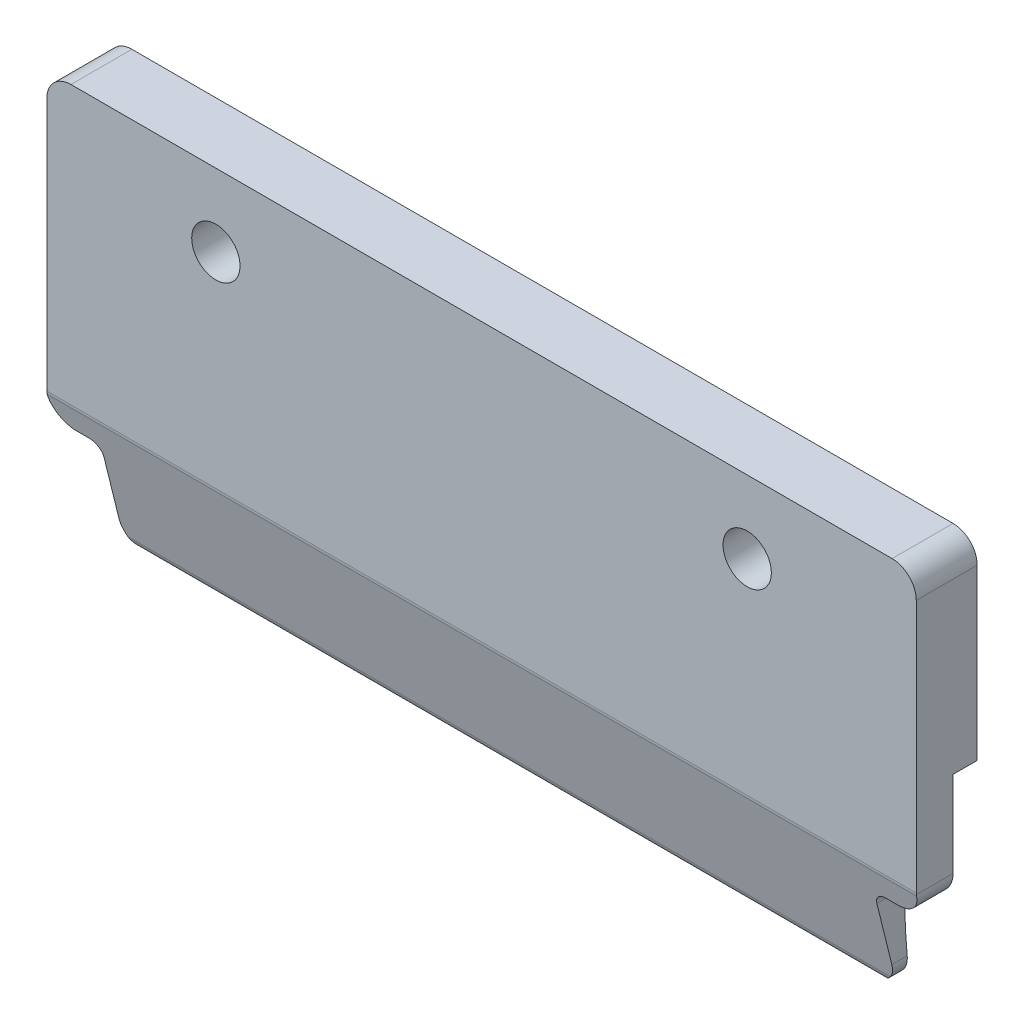
from build123d import *

# Parameters (mm, degrees)
BOSS_EXTRUDE1_DEPTH      = 1.5
BOSS_EXTRUDE1_DEPTH_BACK = 1.2
CUT_EXTRUDE1_DEPTH       = 40
SKETCH11_R               = 1
CUT_EXTRUDE2_DEPTH       = 5


with BuildPart() as part:
    # Sketch1 → Boss-Extrude1 (new body, two sides)
    with BuildSketch(Plane.XY) as boss_extrude1_sk:
        with BuildLine():
            Line((-17.999999991, 9.304537824), (-17.999999991, 10.304506021))
            Line((-17.999999991, 10.304506021), (-17.999999991, 17.303464443))
            ThreePointArc((-17.999999991, 17.303464443), (-17.707106772, 18.010571225), (-16.999999991, 18.303464443))
            Line((-16.999999991, 18.303464443), (16.999968161, 18.303464443))
            ThreePointArc((16.999968161, 18.303464443), (17.707074942, 18.010571225), (17.999968161, 17.303464443))
            Line((17.999968161, 17.303464443), (17.999968161, 9.303464443))
            Line((17.999968161, 9.303464443), (17.999968161, 6.751174458))
            ThreePointArc((17.999968161, 6.751174458), (17.707074942, 6.044067677), (16.999968161, 5.751174458))
            Line((16.999968161, 5.751174458), (16.499999991, 5.751174458))
            ThreePointArc((16.499999991, 5.751174458), (16.1464466, 5.604727849), (15.999999991, 5.251174458))
            Line((15.999999991, 5.251174458), (15.999999991, 2.751174458))
            ThreePointArc((15.999999991, 2.751174458), (15.707106772, 2.044067677), (14.999999991, 1.751174458))
            Line((14.999999991, 1.751174458), (-14.999999991, 1.751174458))
            ThreePointArc((-14.999999991, 1.751174458), (-15.707106772, 2.044067677), (-15.999999991, 2.751174458))
            Line((-15.999999991, 2.751174458), (-15.999999991, 5.251174458))
            ThreePointArc((-15.999999991, 5.251174458), (-16.1464466, 5.604727849), (-16.499999991, 5.751174458))
            Line((-16.499999991, 5.751174458), (-16.999999991, 5.751174458))
            ThreePointArc((-16.999999991, 5.751174458), (-17.707106772, 6.044067677), (-17.999999991, 6.751174458))
            Line((-17.999999991, 6.751174458), (-17.999999991, 9.304537824))
        make_face()
    extrude(amount=BOSS_EXTRUDE1_DEPTH)
    extrude(boss_extrude1_sk.sketch, amount=-BOSS_EXTRUDE1_DEPTH_BACK)

    # Sketch3 → Cut-Extrude1 (cut)
    with BuildSketch(Plane(origin=(17.999968161, 0, 0), x_dir=(0, 0, -1), z_dir=(1, 0, 0))):
        with BuildLine():
            Line((0.023796664, 6.751174458), (0.023796664, 5.754537824))
            ThreePointArc((0.023796664, 5.754537824), (0.053060483, 3.748723952), (0.23729316, 1.751174458))
            Line((0.23729316, 1.751174458), (1.2708887, 1.751174458))
            Line((1.2708887, 1.751174458), (1.2708887, 10.304537824))
            Line((1.2708887, 10.304537824), (1.2708887, 10.30507849))
            ThreePointArc((1.2708887, 10.30507849), (7.212872074, 16.614024598), (1.023796664, 22.680762846))
            Line((1.023796664, 22.680762846), (1.023796664, 17.303464443))
            Line((1.023796664, 17.303464443), (1.2, 17.303464443))
            Line((1.2, 17.303464443), (1.2, 6.751174458))
            Line((1.2, 6.751174458), (0.023796664, 6.751174458))
        make_face()
        Polygon((0.023796664, 10.304537824), (0.023796664, 6.751174458), (1.2, 6.751174458), (1.2, 17.303464443), (1.023796664, 17.303464443), (1.023796664, 10.304537824), align=None)
        with BuildLine():
            ThreePointArc((-1.485404738, 6.692099607), (-1.491731963, 6.721473521), (-1.496283327, 6.751174458))
            Line((-1.496283327, 6.751174458), (-1.5, 6.751174458))
            Line((-1.5, 6.751174458), (-1.5, 1.751174458))
            Line((-1.5, 1.751174458), (0.126821568, 1.751174458))
            ThreePointArc((0.126821568, 1.751174458), (-0.181429151, 1.857497567), (-0.358583171, 2.131248481))
            Line((-0.358583171, 2.131248481), (-1.485404738, 6.692099607))
        make_face()
        with BuildLine():
            Line((-1.5, 6.751174458), (-1.496283327, 6.751174458))
            ThreePointArc((-1.496283327, 6.751174458), (-1.499069967, 6.781543322), (-1.5, 6.812025585))
            Line((-1.5, 6.812025585), (-1.5, 6.751174458))
        make_face()
    extrude(amount=-CUT_EXTRUDE1_DEPTH, mode=Mode.SUBTRACT)

    # Sketch11 → Cut-Extrude2 (cut)
    with BuildSketch(Plane(origin=(0, 0, -1.023796664), x_dir=(-1, 0, 0), z_dir=(0, 0, -1))):
        with Locations((11.000015915, 15.294537824)):
            Circle(SKETCH11_R)
        with Locations((-10.999984085, 15.294537824)):
            Circle(SKETCH11_R)
    extrude(amount=-CUT_EXTRUDE2_DEPTH, mode=Mode.SUBTRACT)


solid = part.part
